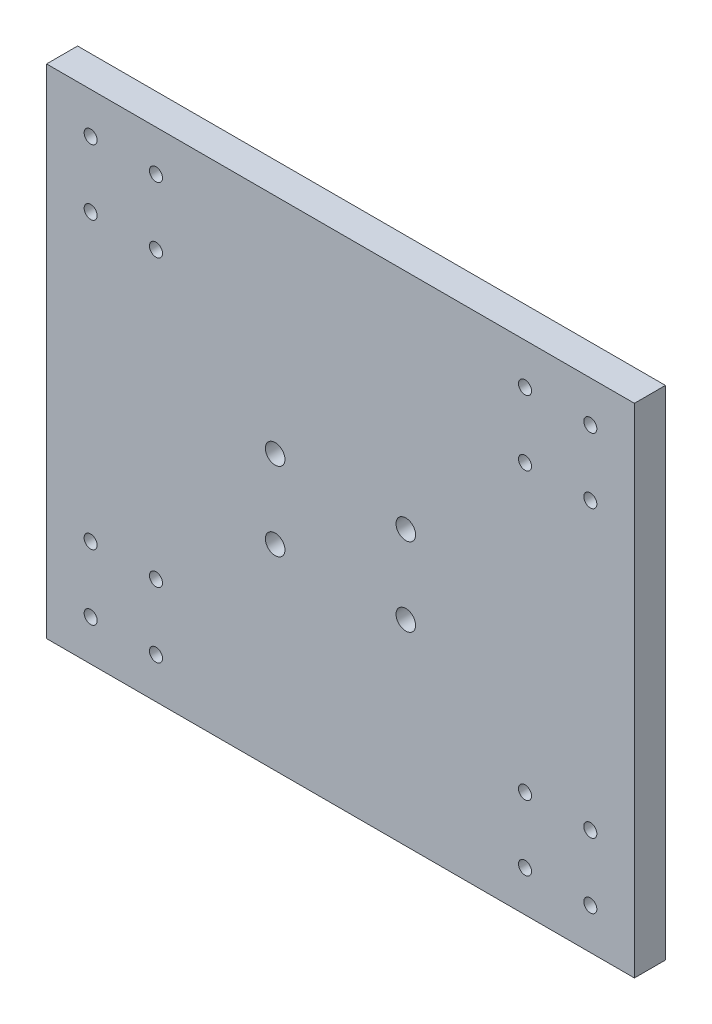
from build123d import *

# Parameters (mm, degrees)
SKETCH1_W           = 180
SKETCH1_H           = 152.4
BOSS_EXTRUDE1_DEPTH = 9.5
SKETCH2_R           = 2
SKETCH2_R_2         = 3
CUT_EXTRUDE1_DEPTH  = 9.5


with BuildPart() as part:
    # Sketch1 → Boss-Extrude1 (new body)
    with BuildSketch(Plane.XY):
        Rectangle(SKETCH1_W, SKETCH1_H)
    extrude(amount=BOSS_EXTRUDE1_DEPTH)

    # Sketch2 → Cut-Extrude1 (cut)
    with BuildSketch(Plane.XY.offset(9.5)):
        with Locations((-76.5, -43.7)):
            Circle(SKETCH2_R)
        with Locations((-56.5, -43.7)):
            Circle(SKETCH2_R)
        with Locations((-76.5, -63.7)):
            Circle(SKETCH2_R)
        with Locations((-56.5, -63.7)):
            Circle(SKETCH2_R)
        with Locations((56.5, -63.7)):
            Circle(SKETCH2_R)
        with Locations((76.5, -63.7)):
            Circle(SKETCH2_R)
        with Locations((56.5, -43.7)):
            Circle(SKETCH2_R)
        with Locations((76.5, -43.7)):
            Circle(SKETCH2_R)
        with Locations((76.5, 43.7)):
            Circle(SKETCH2_R)
        with Locations((56.5, 43.7)):
            Circle(SKETCH2_R)
        with Locations((76.5, 63.7)):
            Circle(SKETCH2_R)
        with Locations((56.5, 63.7)):
            Circle(SKETCH2_R)
        with Locations((-56.5, 63.7)):
            Circle(SKETCH2_R)
        with Locations((-76.5, 63.7)):
            Circle(SKETCH2_R)
        with Locations((-56.5, 43.7)):
            Circle(SKETCH2_R)
        with Locations((-76.5, 43.7)):
            Circle(SKETCH2_R)
        with Locations((-20, 7.8)):
            Circle(SKETCH2_R_2)
        with Locations((20, 7.8)):
            Circle(SKETCH2_R_2)
        with Locations((20, -16.2)):
            Circle(SKETCH2_R_2)
        with Locations((-20, -16.2)):
            Circle(SKETCH2_R_2)
    extrude(amount=-CUT_EXTRUDE1_DEPTH, mode=Mode.SUBTRACT)


solid = part.part
